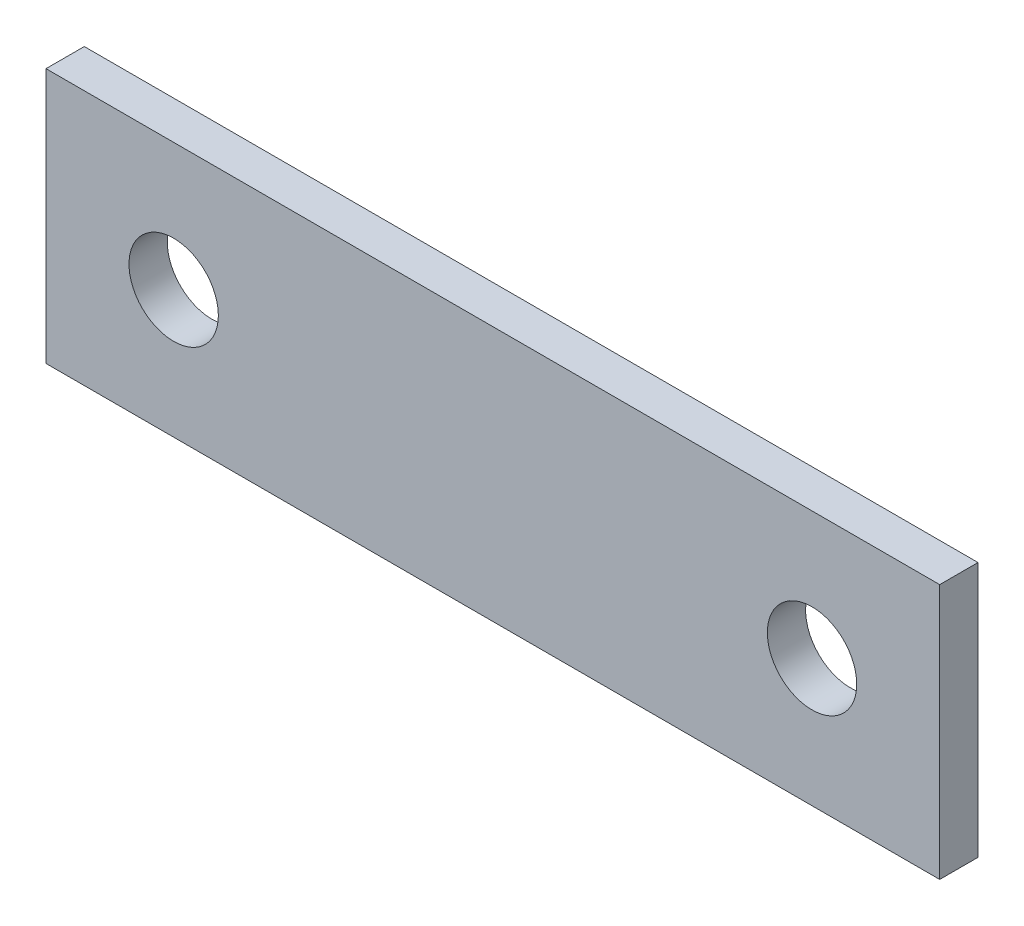
from build123d import *

# Parameters (mm, degrees)
CROQUIS1_W              = 70
CROQUIS1_H              = 20
CROQUIS1_R              = 3.5
SALIENTE_EXTRUIR1_DEPTH = 3


with BuildPart() as part:
    # Croquis1 → Saliente-Extruir1 (new body)
    with BuildSketch(Plane.XY):
        with Locations((-46.888493821, 16.005285962)):
            Rectangle(CROQUIS1_W, CROQUIS1_H)
        with Locations((-71.888493821, 16.005285962)):
            Circle(CROQUIS1_R, mode=Mode.SUBTRACT)
        with Locations((-21.888493821, 16.005285962)):
            Circle(CROQUIS1_R, mode=Mode.SUBTRACT)
    extrude(amount=SALIENTE_EXTRUIR1_DEPTH)


solid = part.part
